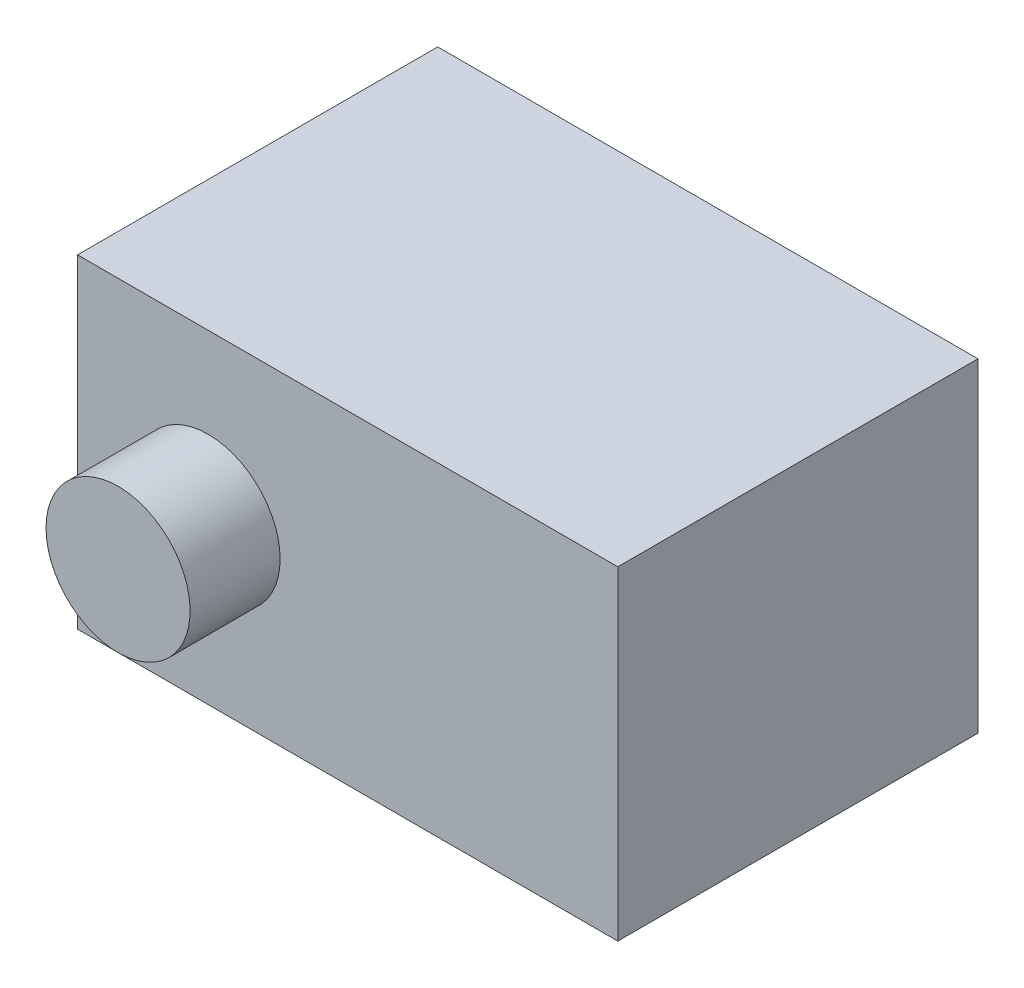
from build123d import *

# Parameters (mm, degrees)
ESQUISSE1_W        = 30
ESQUISSE1_H        = 18
BOSS_EXTRU_1_DEPTH = 20
ESQUISSE2_R        = 4
BOSS_EXTRU_2_DEPTH = 5


with BuildPart() as part:
    # Esquisse1 → Boss.-Extru.1 (new body)
    with BuildSketch(Plane.XY):
        Rectangle(ESQUISSE1_W, ESQUISSE1_H)
    extrude(amount=BOSS_EXTRU_1_DEPTH)

    # Esquisse2 → Boss.-Extru.2 (add)
    with BuildSketch(Plane(origin=(0, 0, 0), x_dir=(-1, 0, 0), z_dir=(0, 0, -1))):
        with Locations((7.75, 0)):
            Circle(ESQUISSE2_R)
    boss_extru_2 = extrude(amount=BOSS_EXTRU_2_DEPTH)

    # Symétrie1: Boss.-Extru.2 across plane
    add(boss_extru_2.mirror(Plane.XY.offset(10)))


solid = part.part
